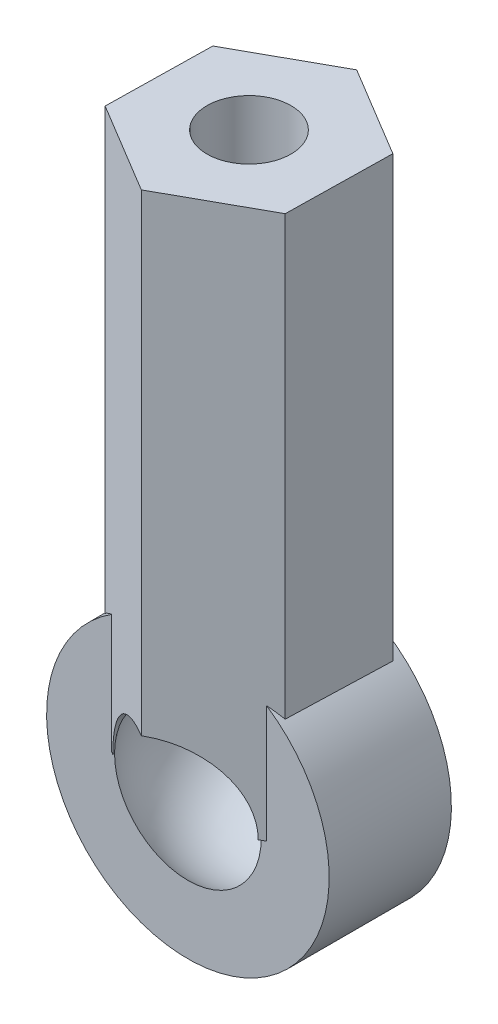
from build123d import *

# Parameters (mm, degrees)
EXTRUDE_1_DEPTH          = 1.6
EXTRUDE_1_DEPTH_BACK     = 1.6
SKETCH_1_R               = 3.7
EXTRUDE_3_DEPTH          = 14.3
SKETCH_9_R               = 1.1
CUT_EXTRUDE_1_DEPTH      = 5
CUT_EXTRUDE_2_DEPTH      = 16.404037189
CUT_EXTRUDE_2_DEPTH_BACK = 16.404037189
SKETCH_10_R              = 1.920937271


with BuildPart() as part:
    # 草圖1 → 填料-伸長1 (new, two sides: drawn at the far end of the back side and taken through both)
    with BuildSketch(Plane.XY.offset(-EXTRUDE_1_DEPTH_BACK)):
        Circle(SKETCH_1_R)
    extrude(amount=EXTRUDE_1_DEPTH + EXTRUDE_1_DEPTH_BACK)

    # 草圖8 → 填料-伸長3 (add)
    with BuildSketch(Plane(origin=(0, 0, 0), x_dir=(1, 0, 0), z_dir=(0, 1, 0))):
        Polygon((0.048682641, 2.770853659), (-2.375288338, 1.427587234), (-2.42397098, -1.343266426), (-0.048682641, -2.770853659), (2.375288338, -1.427587234), (2.42397098, 1.343266426), align=None)
    extrude(amount=EXTRUDE_3_DEPTH)

    # 草圖7 → 除料-旋轉7 (revolve, cut)
    with BuildSketch(Plane.XY):
        with BuildLine():
            Line((0, 2.5), (0, -2.5))
            ThreePointArc((0, -2.5), (2.5, 0), (0, 2.5))
        make_face()
    revolve(axis=Axis((0, 2.5, 0), (0, -1, 0)), mode=Mode.SUBTRACT)

    # 草圖9 → 除料-伸長1 (cut)
    with BuildSketch(Plane(origin=(0, 14.3, 0), x_dir=(1, 0, 0), z_dir=(0, 1, 0))):
        Circle(SKETCH_9_R)
    extrude(amount=-CUT_EXTRUDE_1_DEPTH, mode=Mode.SUBTRACT)

    # 草圖10 → 除料-伸長2 (cut, two sides: drawn at the far end of the back side and taken through both)
    with BuildSketch(Plane(origin=(0, 0, -1.6), x_dir=(-1, 0, 0), z_dir=(0, 0, -1)).offset(-CUT_EXTRUDE_2_DEPTH_BACK)):
        Circle(SKETCH_10_R)
    extrude(amount=CUT_EXTRUDE_2_DEPTH + CUT_EXTRUDE_2_DEPTH_BACK, mode=Mode.SUBTRACT)


solid = part.part
